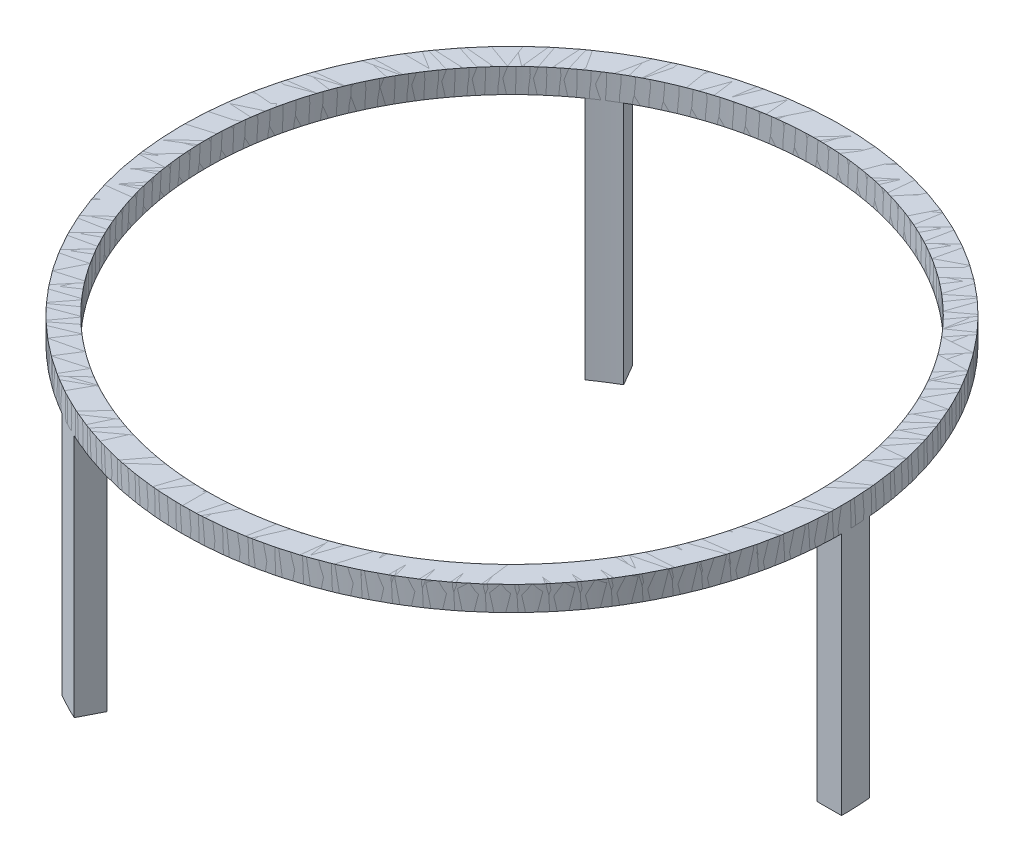
from build123d import *

# Parameters (mm, degrees)
SKETCH2_R           = 135
SKETCH2_R_2         = 125
BOSS_EXTRUDE1_DEPTH = 10
BOSS_EXTRUDE2_DEPTH = 100
CIRPATTERN1_COUNT   = 3


with BuildPart() as part:
    # Sketch2 → Boss-Extrude1 (new body)
    with BuildSketch(Plane(origin=(0, 0, 0), x_dir=(1, 0, 0), z_dir=(0, 1, 0))):
        Circle(SKETCH2_R)
        Circle(SKETCH2_R_2, mode=Mode.SUBTRACT)
    extrude(amount=BOSS_EXTRUDE1_DEPTH)

    # Sketch4 → Boss-Extrude2 (add)
    with BuildSketch(Plane.XZ):
        with BuildLine():
            Line((125, 0), (134.999998466, -0.020349279))
            ThreePointArc((134.999998466, -0.020349279), (134.868029655, -5.967794984), (134.474172467, -11.903652353))
            Line((134.474172467, -11.903652353), (124.478495141, -11.406324891))
            ThreePointArc((124.478495141, -11.406324891), (124.869555722, -5.709120222), (125, 0))
        make_face()
    extrude(amount=BOSS_EXTRUDE2_DEPTH)


with BuildPart() as cirpattern1_1:
    # CirPattern1: pattern copy
    add(part.part.rotate(Axis((0, 0, 0), (0, 1, 0)), 1 * 360 / CIRPATTERN1_COUNT))


with BuildPart() as cirpattern1_2:
    # CirPattern1: pattern copy
    add(part.part.rotate(Axis((0, 0, 0), (0, 1, 0)), 2 * 360 / CIRPATTERN1_COUNT))


solid = Compound([part.part, cirpattern1_1.part, cirpattern1_2.part])
